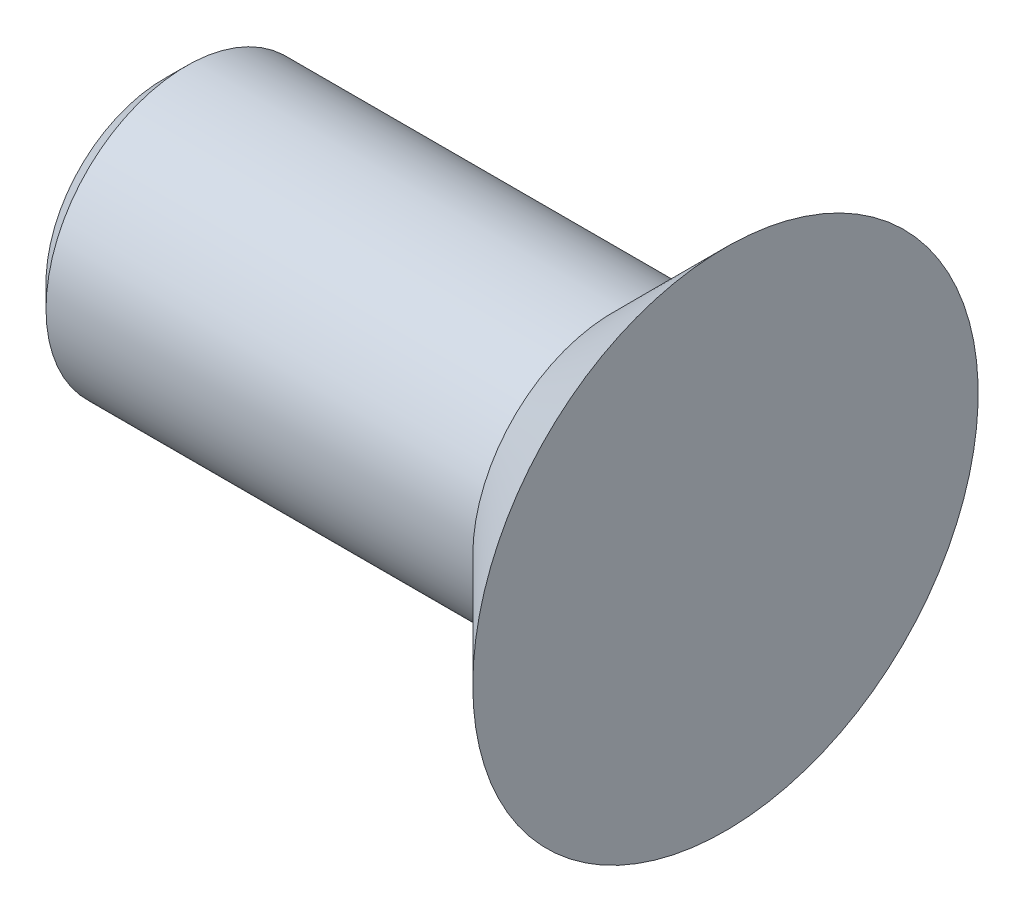
from build123d import *

# Parameters (mm, degrees)
CHANFREIN1_SIZE = 0.4


with BuildPart() as part:
    # Esquisse1 → Révolution1 (revolve)
    with BuildSketch(Plane.XY, mode=Mode.PRIVATE) as r_volution1_sk:
        Polygon((0, 0), (-10, 0), (-10, 2.5), (-2, 2.5), (0, 4.5), align=None)
    revolve(r_volution1_sk.sketch.rotate(Axis((0, 0, 0), (1, 0, 0)), 90), axis=Axis((0, 0, 0), (1, 0, 0)))  # turned: the seam where the file's is

    # Chanfrein1
    chanfrein1_edges = [part.edges().sort_by_distance(p)[0] for p in [
        (-10, 0, -2.5),
    ]]
    chamfer(chanfrein1_edges, length=CHANFREIN1_SIZE)


solid = part.part
